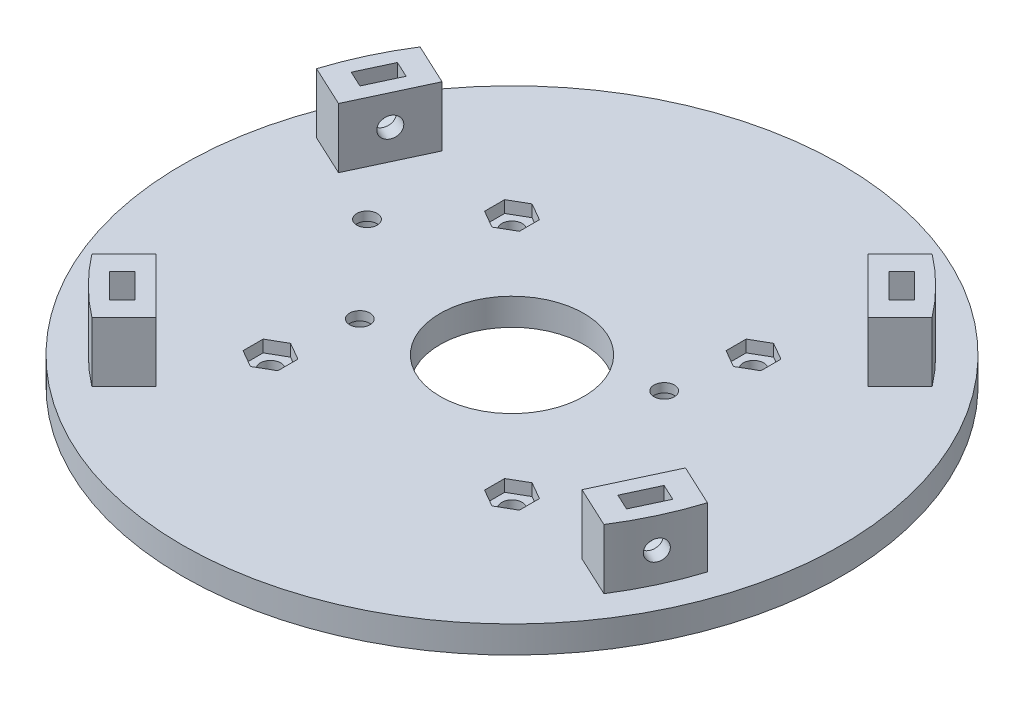
from build123d import *

# Parameters (mm, degrees)
CROQUIS1_W               = 43
CROQUIS1_H               = 4.5
CROQUIS2_R               = 1.7
CORTAR_EXTRUIR1_DEPTH    = 10
CORTAR_EXTRUIR2_DEPTH    = 2
CROQUIS4_R               = 2.95
CORTAR_EXTRUIR3_DEPTH    = 3
SALIENTE_EXTRUIR1_DEPTH  = 10
CROQUIS6_R               = 1.7
CORTAR_EXTRUIR4_DEPTH    = 10
CORTAR_EXTRUIR5_DEPTH    = 1.5
MATRIZC1_COUNT           = 2
MATRIZC1_ANGLE           = 70
MATRIZC2_COPY_1_DEPTH    = 10
MATRIZC2_COPY_2_SKETCH_R = 1.7
MATRIZC2_COPY_2_DEPTH    = 10
MATRIZC2_COPY_3_DEPTH    = 1.5
MATRIZC2_COPY_4_DEPTH    = 10
MATRIZC2_COPY_5_SKETCH_R = 1.7
MATRIZC2_COPY_5_DEPTH    = 10
MATRIZC2_COPY_6_DEPTH    = 1.5


with BuildPart() as part:
    # Croquis1 → Revolución1 (revolve)
    with BuildSketch(Plane.XY):
        with Locations((33.5, 2.25)):
            Rectangle(CROQUIS1_W, CROQUIS1_H)
    revolve(axis=Axis((0, 115.94715176, 0), (0, -1, 0)))

    # Croquis2 → Cortar-Extruir1 (cut)
    with BuildSketch(Plane(origin=(0, 4.5, 0), x_dir=(1, 0, 0), z_dir=(0, 1, 0))):
        with Locations((-31.7, 7.5)):
            Circle(CROQUIS2_R)
        with Locations((17.9, 7.5)):
            Circle(CROQUIS2_R)
        with Locations((-17.9, -7.5)):
            Circle(CROQUIS2_R)
        with Locations((31.7, -7.5)):
            Circle(CROQUIS2_R)
        with Locations((20.152543264, 20.152543264)):
            Circle(CROQUIS2_R)
        with Locations((-20.152543264, 20.152543264)):
            Circle(CROQUIS2_R)
        with Locations((-20.152543264, -20.152543264)):
            Circle(CROQUIS2_R)
        with Locations((20.152543264, -20.152543264)):
            Circle(CROQUIS2_R)
    extrude(amount=-CORTAR_EXTRUIR1_DEPTH, mode=Mode.SUBTRACT)

    # Croquis3 → Cortar-Extruir2 (cut)
    with BuildSketch(Plane(origin=(0, 4.5, 0), x_dir=(1, 0, 0), z_dir=(0, 1, 0))):
        Polygon((-20.152543264, 23.502543264), (-23.053728366, 21.827543264), (-23.053728366, 18.477543264), (-20.152543264, 16.802543264), (-17.251358161, 18.477543264), (-17.251358161, 21.827543264), align=None)
        Polygon((20.152543264, 23.502543264), (17.251358161, 21.827543264), (17.251358161, 18.477543264), (20.152543264, 16.802543264), (23.053728366, 18.477543264), (23.053728366, 21.827543264), align=None)
        Polygon((-20.152543264, -16.802543264), (-23.053728366, -18.477543264), (-23.053728366, -21.827543264), (-20.152543264, -23.502543264), (-17.251358161, -21.827543264), (-17.251358161, -18.477543264), align=None)
        Polygon((20.152543264, -16.802543264), (17.251358161, -18.477543264), (17.251358161, -21.827543264), (20.152543264, -23.502543264), (23.053728366, -21.827543264), (23.053728366, -18.477543264), align=None)
    extrude(amount=-CORTAR_EXTRUIR2_DEPTH, mode=Mode.SUBTRACT)

    # Croquis4 → Cortar-Extruir3 (cut)
    with BuildSketch(Plane(origin=(0, 0, 0), x_dir=(1, 0, 0), z_dir=(0, 1, 0))):
        with Locations((-31.7, 7.5)):
            Circle(CROQUIS4_R)
        with Locations((-17.9, -7.5)):
            Circle(CROQUIS4_R)
        with Locations((17.9, 7.5)):
            Circle(CROQUIS4_R)
        with Locations((31.7, -7.5)):
            Circle(CROQUIS4_R)
    extrude(amount=CORTAR_EXTRUIR3_DEPTH, mode=Mode.SUBTRACT)

    # Croquis5 → Saliente-Extruir1 (add)
    with BuildSketch(Plane(origin=(0, 4.5, 0), x_dir=(1, 0, 0), z_dir=(0, 1, 0))):
        with BuildLine():
            Line((-34.294678888, -25.102290732), (-25.102290732, -34.294678888))
            Line((-25.102290732, -34.294678888), (-30.459119357, -39.651507512))
            ThreePointArc((-30.459119357, -39.651507512), (-35.355339059, -35.355339059), (-39.651507512, -30.459119357))
            Line((-39.651507512, -30.459119357), (-34.294678888, -25.102290732))
        make_face()
    saliente_extruir1 = extrude(amount=SALIENTE_EXTRUIR1_DEPTH)

    # Croquis6 → Cortar-Extruir4 (cut)
    with BuildSketch(Plane(origin=(-29.69848481, 0, 29.69848481), x_dir=(-0.7071067811865479, 0, -0.7071067811865472), z_dir=(0.7071067811865472, 0, -0.7071067811865479))):
        with Locations((0, 9.5)):
            Circle(CROQUIS6_R)
    cortar_extruir4 = extrude(amount=-CORTAR_EXTRUIR4_DEPTH, mode=Mode.SUBTRACT)

    # Croquis7 → Cortar-Extruir5 (cut, symmetric)
    with BuildSketch(Plane(origin=(-32.526911935, 0, 32.526911935), x_dir=(0.7071067811865478, 0, 0.7071067811865472), z_dir=(-0.7071067811865472, 0, 0.7071067811865478))):
        Polygon((-2.901185103, 11.175), (-2.901185103, 17.825), (2.901185103, 17.825), (2.901185103, 11.175), (2.901185103, 7.825), (0, 6.15), (-2.901185103, 7.825), align=None)
    cortar_extruir5 = extrude(amount=CORTAR_EXTRUIR5_DEPTH, both=True, mode=Mode.SUBTRACT)

    # MatrizC1: Saliente-Extruir1, Cortar-Extruir4, Cortar-Extruir5 ×2 about axis
    matrizc1_axis = Axis((0, 115.94715176, 0), (0, -1, 0))
    add([saliente_extruir1.rotate(matrizc1_axis, i * MATRIZC1_ANGLE / (MATRIZC1_COUNT - 1)) for i in range(1, MATRIZC1_COUNT)])
    add([cortar_extruir4.rotate(matrizc1_axis, i * MATRIZC1_ANGLE / (MATRIZC1_COUNT - 1)) for i in range(1, MATRIZC1_COUNT)], mode=Mode.SUBTRACT)
    add([cortar_extruir5.rotate(matrizc1_axis, i * MATRIZC1_ANGLE / (MATRIZC1_COUNT - 1)) for i in range(1, MATRIZC1_COUNT)], mode=Mode.SUBTRACT)

    # MatrizC2 copy 1 sketch → MatrizC2 copy 1 (add)
    with BuildSketch(Plane(origin=(0, 4.5, 0), x_dir=(-0.342020143325666, 0, -0.9396926207859093), z_dir=(0, 1, 0))):
        with BuildLine():
            Line((-34.294678888, -25.102290732), (-25.102290732, -34.294678888))
            Line((-25.102290732, -34.294678888), (-30.459119357, -39.651507512))
            ThreePointArc((-30.459119357, -39.651507512), (-35.355339059, -35.355339059), (-39.651507512, -30.459119357))
            Line((-39.651507512, -30.459119357), (-34.294678888, -25.102290732))
        make_face()
    extrude(amount=MATRIZC2_COPY_1_DEPTH)

    # MatrizC2 copy 2 sketch → MatrizC2 copy 2 (cut)
    with BuildSketch(Plane(origin=(38.064927056, 0, 17.749966993), x_dir=(-0.42261826174070166, 0, 0.9063077870366489), z_dir=(-0.9063077870366489, 0, -0.42261826174070166))):
        with Locations((0, 9.5)):
            Circle(MATRIZC2_COPY_2_SKETCH_R)
    extrude(amount=-MATRIZC2_COPY_2_DEPTH, mode=Mode.SUBTRACT)

    # MatrizC2 copy 3 sketch → MatrizC2 copy 3 (cut, symmetric)
    with BuildSketch(Plane(origin=(41.690158204, 0, 19.44044004), x_dir=(0.4226182617407017, 0, -0.9063077870366489), z_dir=(0.9063077870366489, 0, 0.4226182617407017))):
        Polygon((-2.901185103, 11.175), (-2.901185103, 17.825), (2.901185103, 17.825), (2.901185103, 11.175), (2.901185103, 7.825), (0, 6.15), (-2.901185103, 7.825), align=None)
    extrude(amount=MATRIZC2_COPY_3_DEPTH, both=True, mode=Mode.SUBTRACT)

    # MatrizC2 copy 4 sketch → MatrizC2 copy 4 (add)
    with BuildSketch(Plane(origin=(0, 4.5, 0), x_dir=(-1, 0, 0), z_dir=(0, 1, 0))):
        with BuildLine():
            Line((-34.294678888, -25.102290732), (-25.102290732, -34.294678888))
            Line((-25.102290732, -34.294678888), (-30.459119357, -39.651507512))
            ThreePointArc((-30.459119357, -39.651507512), (-35.355339059, -35.355339059), (-39.651507512, -30.459119357))
            Line((-39.651507512, -30.459119357), (-34.294678888, -25.102290732))
        make_face()
    extrude(amount=MATRIZC2_COPY_4_DEPTH)

    # MatrizC2 copy 5 sketch → MatrizC2 copy 5 (cut)
    with BuildSketch(Plane(origin=(29.69848481, 0, -29.69848481), x_dir=(0.7071067811865478, 0, 0.7071067811865474), z_dir=(-0.7071067811865474, 0, 0.7071067811865478))):
        with Locations((0, 9.5)):
            Circle(MATRIZC2_COPY_5_SKETCH_R)
    extrude(amount=-MATRIZC2_COPY_5_DEPTH, mode=Mode.SUBTRACT)

    # MatrizC2 copy 6 sketch → MatrizC2 copy 6 (cut, symmetric)
    with BuildSketch(Plane(origin=(32.526911935, 0, -32.526911935), x_dir=(-0.7071067811865477, 0, -0.7071067811865474), z_dir=(0.7071067811865474, 0, -0.7071067811865477))):
        Polygon((-2.901185103, 11.175), (-2.901185103, 17.825), (2.901185103, 17.825), (2.901185103, 11.175), (2.901185103, 7.825), (0, 6.15), (-2.901185103, 7.825), align=None)
    extrude(amount=MATRIZC2_COPY_6_DEPTH, both=True, mode=Mode.SUBTRACT)


solid = part.part
